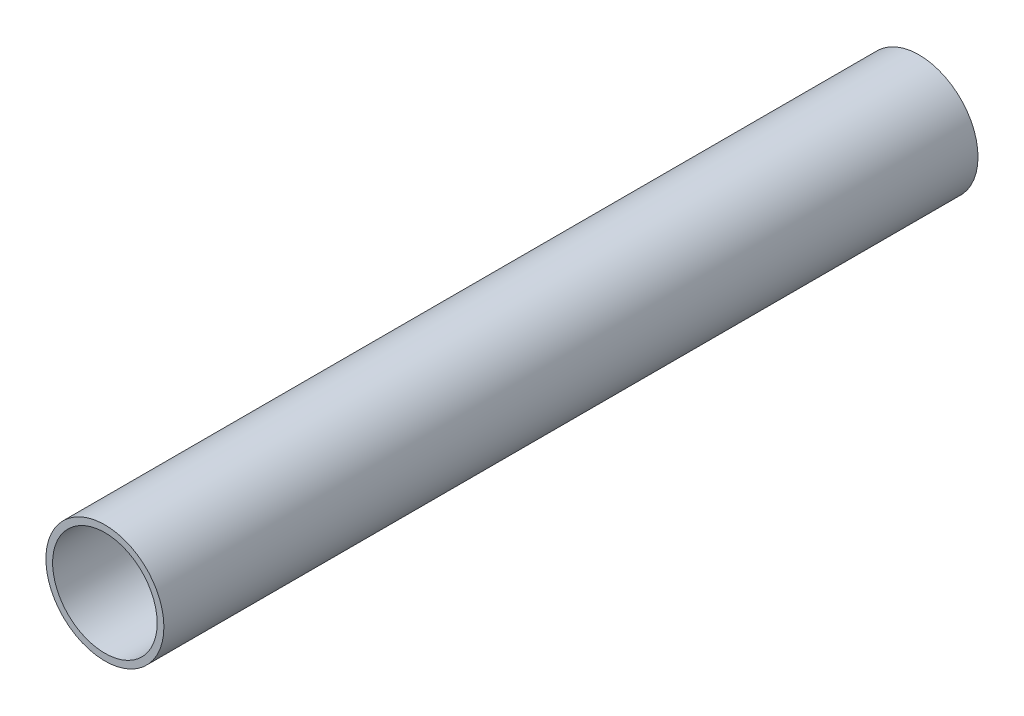
from build123d import *

# Parameters (mm, degrees)
CROQUIS1_R              = 17.54
CROQUIS1_R_2            = 15.54
SALIENTE_EXTRUIR1_DEPTH = 242


with BuildPart() as part:
    # Croquis1 → Saliente-Extruir1 (new body)
    with BuildSketch(Plane.XY):
        Circle(CROQUIS1_R)
        Circle(CROQUIS1_R_2, mode=Mode.SUBTRACT)
    extrude(amount=SALIENTE_EXTRUIR1_DEPTH)


solid = part.part
